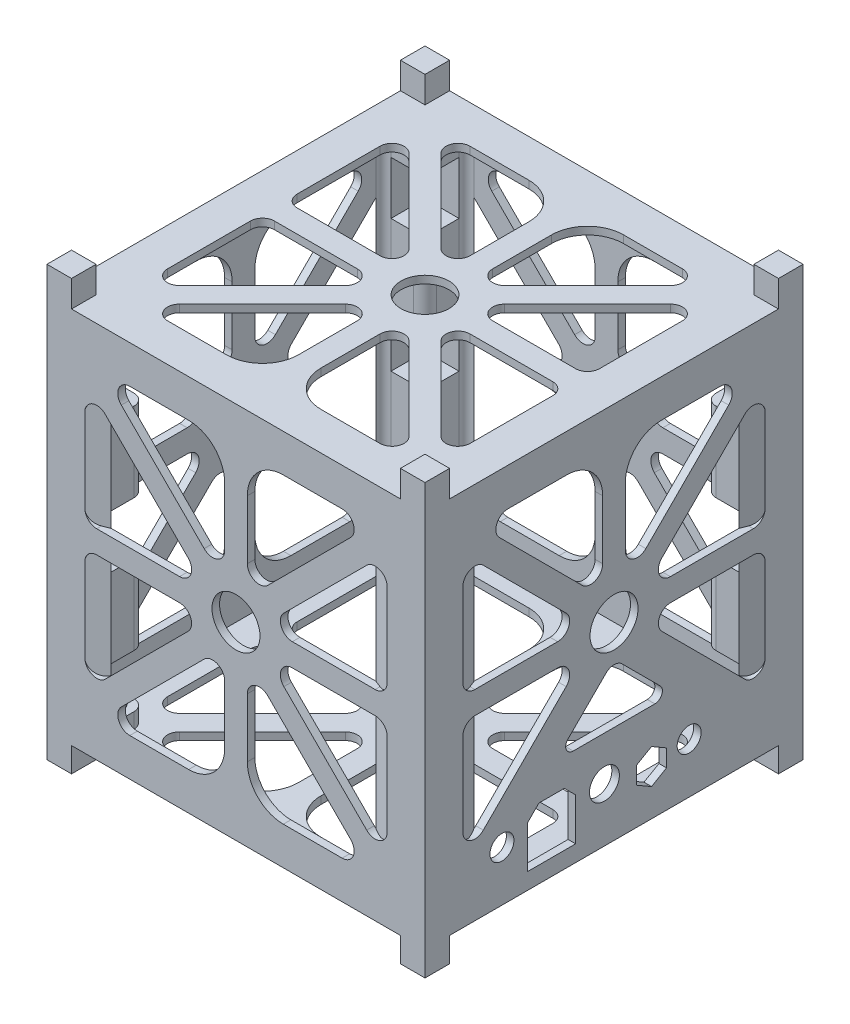
from build123d import *

# Parameters (mm, degrees)
SKETCH1_W                = 100
SKETCH1_H                = 100
BOSS_EXTRUDE1_DEPTH      = 50
SKETCH2_W                = 6.5
SKETCH2_H                = 6.5
BOSS_EXTRUDE2_DEPTH      = 57
BOSS_EXTRUDE2_DEPTH_BACK = 56.5
SKETCH4_W                = 96
SKETCH4_H                = 96
CUT_EXTRUDE1_DEPTH       = 96
SKETCH6_R                = 6.35
CUT_EXTRUDE4_DEPTH       = 2
CUT_EXTRUDE2_REACH       = 102
SKETCH5_R                = 3.175
SKETCH5_R_2              = 3.9624
SKETCH5_R_3              = 6.35
BOSS_EXTRUDE3_REACH      = 106.5
CUT_EXTRUDE5_START       = 78
SKETCH10_R               = 1.5
CUT_EXTRUDE5_DEPTH       = 2
CUT_EXTRUDE6_START       = 80
SKETCH13_R               = 1.5
CUT_EXTRUDE6_DEPTH       = 12
CUT_EXTRUDE7_START       = 80
SKETCH13_3_R             = 1.5
CUT_EXTRUDE7_DEPTH       = 14
BOSS_EXTRUDE4_DEPTH      = 100
MIRROR6_COPY_1_DEPTH     = 100
MIRROR6_COPY_2_DEPTH     = 100
MIRROR7_COPY_1_DEPTH     = 100
MIRROR7_COPY_2_DEPTH     = 100
MIRROR7_COPY_3_DEPTH     = 100
CUT_EXTRUDE11_DEPTH      = 3
BOSS_EXTRUDE5_DEPTH      = 98
SKETCH18_R               = 6.35
CUT_EXTRUDE13_DEPTH      = 107.5
LPATTERN1_COUNT          = 3
LPATTERN1_PITCH          = 35


with BuildPart() as part:
    # Sketch1 → Boss-Extrude1 (new body, symmetric)
    with BuildSketch(Plane(origin=(0, 0, 0), x_dir=(1, 0, 0), z_dir=(0, 1, 0))):
        Rectangle(SKETCH1_W, SKETCH1_H)
    extrude(amount=BOSS_EXTRUDE1_DEPTH, both=True)

    # Sketch2 → Boss-Extrude2 (add, two sides)
    with BuildSketch(Plane(origin=(0, 0, 0), x_dir=(1, 0, 0), z_dir=(0, 1, 0))) as boss_extrude2_sk:
        with Locations((-46.75, -46.75)):
            Rectangle(SKETCH2_W, SKETCH2_H)
        with Locations((46.75, -46.75)):
            Rectangle(SKETCH2_W, SKETCH2_H)
        with Locations((46.75, 46.75)):
            Rectangle(SKETCH2_W, SKETCH2_H)
        with Locations((-46.75, 46.75)):
            Rectangle(SKETCH2_W, SKETCH2_H)
    extrude(amount=BOSS_EXTRUDE2_DEPTH)
    extrude(boss_extrude2_sk.sketch, amount=-BOSS_EXTRUDE2_DEPTH_BACK)

    # Sketch4 → Cut-Extrude1 (cut)
    with BuildSketch(Plane(origin=(48, 0, 0), x_dir=(0, 0, -1), z_dir=(1, 0, 0))):
        Rectangle(SKETCH4_W, SKETCH4_H)
    extrude(amount=-CUT_EXTRUDE1_DEPTH, mode=Mode.SUBTRACT)

    # Sketch6 → Cut-Extrude4 (cut)
    with BuildSketch(Plane.XY.offset(50)):
        with BuildLine():
            ThreePointArc((-3, -30.475), (-5.789807909, -37.210192091), (-12.525, -40))
            Line((-12.525, -40), (-28.092231252, -40))
            ThreePointArc((-28.092231252, -40), (-31.025548768, -38.040019898), (-30.337295283, -34.57993597))
            Line((-30.337295283, -34.57993597), (-8.42006403, -12.662704717))
            ThreePointArc((-8.42006403, -12.662704717), (-4.959980102, -11.974451232), (-3, -14.907768748))
            Line((-3, -14.907768748), (-3, -30.475))
        make_face()
        with BuildLine():
            ThreePointArc((-14.907768748, -3), (-11.974451232, -4.959980102), (-12.662704717, -8.42006403))
            Line((-12.662704717, -8.42006403), (-34.57993597, -30.337295283))
            ThreePointArc((-34.57993597, -30.337295283), (-38.040019898, -31.025548768), (-40, -28.092231252))
            Line((-40, -28.092231252), (-40, -6.175))
            ThreePointArc((-40, -6.175), (-39.07006403, -3.92993597), (-36.825, -3))
            Line((-36.825, -3), (-14.907768748, -3))
        make_face()
        with BuildLine():
            ThreePointArc((-40, 28.092231252), (-38.040019898, 31.025548768), (-34.57993597, 30.337295283))
            Line((-34.57993597, 30.337295283), (-12.662704717, 8.42006403))
            ThreePointArc((-12.662704717, 8.42006403), (-11.974451232, 4.959980102), (-14.907768748, 3))
            Line((-14.907768748, 3), (-36.825, 3))
            ThreePointArc((-36.825, 3), (-39.07006403, 3.92993597), (-40, 6.175))
            Line((-40, 6.175), (-40, 28.092231252))
        make_face()
        with BuildLine():
            Line((-30.337295283, 34.57993597), (-8.42006403, 12.662704717))
            ThreePointArc((-8.42006403, 12.662704717), (-4.959980102, 11.974451232), (-3, 14.907768748))
            Line((-3, 14.907768748), (-3, 30.475))
            ThreePointArc((-3, 30.475), (-5.789807909, 37.210192091), (-12.525, 40))
            Line((-12.525, 40), (-28.092231252, 40))
            ThreePointArc((-28.092231252, 40), (-31.025548768, 38.040019898), (-30.337295283, 34.57993597))
        make_face()
        with BuildLine():
            Line((30.337295283, 34.57993597), (8.42006403, 12.662704717))
            ThreePointArc((8.42006403, 12.662704717), (4.959980102, 11.974451232), (3, 14.907768748))
            Line((3, 14.907768748), (3, 30.475))
            ThreePointArc((3, 30.475), (5.789807909, 37.210192091), (12.525, 40))
            Line((12.525, 40), (28.092231252, 40))
            ThreePointArc((28.092231252, 40), (31.025548768, 38.040019898), (30.337295283, 34.57993597))
        make_face()
        with BuildLine():
            Line((12.662704717, 8.42006403), (34.57993597, 30.337295283))
            ThreePointArc((34.57993597, 30.337295283), (38.040019898, 31.025548768), (40, 28.092231252))
            Line((40, 28.092231252), (40, 6.175))
            ThreePointArc((40, 6.175), (39.07006403, 3.92993597), (36.825, 3))
            Line((36.825, 3), (14.907768748, 3))
            ThreePointArc((14.907768748, 3), (11.974451232, 4.959980102), (12.662704717, 8.42006403))
        make_face()
        with BuildLine():
            Line((34.57993597, -30.337295283), (12.662704717, -8.42006403))
            ThreePointArc((12.662704717, -8.42006403), (11.974451232, -4.959980102), (14.907768748, -3))
            Line((14.907768748, -3), (36.825, -3))
            ThreePointArc((36.825, -3), (39.07006403, -3.92993597), (40, -6.175))
            Line((40, -6.175), (40, -28.092231252))
            ThreePointArc((40, -28.092231252), (38.040019898, -31.025548768), (34.57993597, -30.337295283))
        make_face()
        with BuildLine():
            ThreePointArc((30.337295283, -34.57993597), (31.025548768, -38.040019898), (28.092231252, -40))
            Line((28.092231252, -40), (12.525, -40))
            ThreePointArc((12.525, -40), (5.789807909, -37.210192091), (3, -30.475))
            Line((3, -30.475), (3, -14.907768748))
            ThreePointArc((3, -14.907768748), (4.959980102, -11.974451232), (8.42006403, -12.662704717))
            Line((8.42006403, -12.662704717), (30.337295283, -34.57993597))
        make_face()
        Circle(SKETCH6_R)
    cut_extrude4 = extrude(amount=-CUT_EXTRUDE4_DEPTH, mode=Mode.SUBTRACT)

    # Sketch5 → Cut-Extrude2 (cut, up to next)
    with BuildSketch(Plane(origin=(50, 0, 0), x_dir=(0, 0, -1), z_dir=(1, 0, 0)), mode=Mode.PRIVATE) as cut_extrude2_sk1:
        with BuildLine():
            Line((-3, 14.907768748), (-3, 30.475))
            ThreePointArc((-3, 30.475), (-5.789807909, 37.210192091), (-12.525, 40))
            Line((-12.525, 40), (-28.092231252, 40))
            ThreePointArc((-28.092231252, 40), (-31.025548768, 38.040019898), (-30.337295283, 34.57993597))
            Line((-30.337295283, 34.57993597), (-8.42006403, 12.662704717))
            ThreePointArc((-8.42006403, 12.662704717), (-4.959980102, 11.974451232), (-3, 14.907768748))
        make_face()
    cut_extrude2_tool1 = extrude(cut_extrude2_sk1.sketch, amount=-CUT_EXTRUDE2_REACH, mode=Mode.PRIVATE) & part.part
    add(cut_extrude2_tool1.solids().sort_by_distance((50, 28.959024, 14.040976))[0], mode=Mode.SUBTRACT)
    # Sketch5 → Cut-Extrude2 (cut, up to next)
    with BuildSketch(Plane(origin=(50, 0, 0), x_dir=(0, 0, -1), z_dir=(1, 0, 0)), mode=Mode.PRIVATE) as cut_extrude2_sk2:
        Polygon((-10.156, -34.48), (-13.156, -31.48), (-19.864, -31.48), (-22.864, -34.48), (-22.864, -45.686), (-10.156, -45.686), align=None)
    cut_extrude2_tool2 = extrude(cut_extrude2_sk2.sketch, amount=-CUT_EXTRUDE2_REACH, mode=Mode.PRIVATE) & part.part
    add(cut_extrude2_tool2.solids().sort_by_distance((50, -38.903218, 16.51))[0], mode=Mode.SUBTRACT)
    # Sketch5 → Cut-Extrude2 (cut, up to next)
    with BuildSketch(Plane(origin=(50, 0, 0), x_dir=(0, 0, -1), z_dir=(1, 0, 0)), mode=Mode.PRIVATE) as cut_extrude2_sk3:
        with BuildLine():
            Line((40, -28.092231252), (40, -6.175))
            ThreePointArc((40, -6.175), (39.07006403, -3.92993597), (36.825, -3))
            Line((36.825, -3), (14.907768748, -3))
            ThreePointArc((14.907768748, -3), (11.974451232, -4.959980102), (12.662704717, -8.42006403))
            Line((12.662704717, -8.42006403), (34.57993597, -30.337295283))
            ThreePointArc((34.57993597, -30.337295283), (38.040019898, -31.025548768), (40, -28.092231252))
        make_face()
    cut_extrude2_tool3 = extrude(cut_extrude2_sk3.sketch, amount=-CUT_EXTRUDE2_REACH, mode=Mode.PRIVATE) & part.part
    add(cut_extrude2_tool3.solids().sort_by_distance((50, -13.744194, -29.255806))[0], mode=Mode.SUBTRACT)
    # Sketch5 → Cut-Extrude2 (cut, up to next)
    with BuildSketch(Plane(origin=(50, 0, 0), x_dir=(0, 0, -1), z_dir=(1, 0, 0)), mode=Mode.PRIVATE) as cut_extrude2_sk4:
        with BuildLine():
            ThreePointArc((-40, -28.092231252), (-38.040019898, -31.025548768), (-34.57993597, -30.337295283))
            Line((-34.57993597, -30.337295283), (-12.662704717, -8.42006403))
            ThreePointArc((-12.662704717, -8.42006403), (-11.974451232, -4.959980102), (-14.907768748, -3))
            Line((-14.907768748, -3), (-36.825, -3))
            ThreePointArc((-36.825, -3), (-39.07006403, -3.92993597), (-40, -6.175))
            Line((-40, -6.175), (-40, -28.092231252))
        make_face()
    cut_extrude2_tool4 = extrude(cut_extrude2_sk4.sketch, amount=-CUT_EXTRUDE2_REACH, mode=Mode.PRIVATE) & part.part
    add(cut_extrude2_tool4.solids().sort_by_distance((50, -13.744194, 29.255806))[0], mode=Mode.SUBTRACT)
    # Sketch5 → Cut-Extrude2 (cut, up to next)
    with BuildSketch(Plane(origin=(50, 0, 0), x_dir=(0, 0, -1), z_dir=(1, 0, 0)), mode=Mode.PRIVATE) as cut_extrude2_sk5:
        with BuildLine():
            ThreePointArc((-40, 6.175), (-39.07006403, 3.92993597), (-36.825, 3))
            Line((-36.825, 3), (-14.907768748, 3))
            ThreePointArc((-14.907768748, 3), (-11.974451232, 4.959980102), (-12.662704717, 8.42006403))
            Line((-12.662704717, 8.42006403), (-34.57993597, 30.337295283))
            ThreePointArc((-34.57993597, 30.337295283), (-38.040019898, 31.025548768), (-40, 28.092231252))
            Line((-40, 28.092231252), (-40, 6.175))
        make_face()
    cut_extrude2_tool5 = extrude(cut_extrude2_sk5.sketch, amount=-CUT_EXTRUDE2_REACH, mode=Mode.PRIVATE) & part.part
    add(cut_extrude2_tool5.solids().sort_by_distance((50, 13.744194, 29.255806))[0], mode=Mode.SUBTRACT)
    # Sketch5 → Cut-Extrude2 (cut, up to next)
    with BuildSketch(Plane(origin=(50, 0, 0), x_dir=(0, 0, -1), z_dir=(1, 0, 0)), mode=Mode.PRIVATE) as cut_extrude2_sk6:
        with BuildLine():
            Line((12.213897948, -20.692427125), (2.124696443, -10.603225619))
            ThreePointArc((2.124696443, -10.603225619), (0.003376099, -9.724545962), (-2.117944245, -10.603225619))
            Line((-2.117944245, -10.603225619), (-12.207145751, -20.692427125))
            ThreePointArc((-12.207145751, -20.692427125), (-12.640691253, -22.872007552), (-10.792932188, -24.106640687))
            Line((-10.792932188, -24.106640687), (10.799684386, -24.106640687))
            ThreePointArc((10.799684386, -24.106640687), (12.647443451, -22.872007552), (12.213897948, -20.692427125))
        make_face()
    cut_extrude2_tool6 = extrude(cut_extrude2_sk6.sketch, amount=-CUT_EXTRUDE2_REACH, mode=Mode.PRIVATE) & part.part
    add(cut_extrude2_tool6.solids().sort_by_distance((50, -18.793244, -0.003376))[0], mode=Mode.SUBTRACT)
    # Sketch5 → Cut-Extrude2 (cut, up to next)
    with BuildSketch(Plane(origin=(50, 0, 0), x_dir=(0, 0, -1), z_dir=(1, 0, 0)), mode=Mode.PRIVATE) as cut_extrude2_sk7:
        with Locations((-29.65, -36.726)):
            Circle(SKETCH5_R)
    cut_extrude2_tool7 = extrude(cut_extrude2_sk7.sketch, amount=-CUT_EXTRUDE2_REACH, mode=Mode.PRIVATE) & part.part
    add(cut_extrude2_tool7.solids().sort_by_distance((50, -36.726, 29.65))[0], mode=Mode.SUBTRACT)
    # Sketch5 → Cut-Extrude2 (cut, up to next)
    with BuildSketch(Plane(origin=(50, 0, 0), x_dir=(0, 0, -1), z_dir=(1, 0, 0)), mode=Mode.PRIVATE) as cut_extrude2_sk8:
        with BuildLine():
            Line((3, 30.475), (3, 14.907768748))
            ThreePointArc((3, 14.907768748), (4.959980102, 11.974451232), (8.42006403, 12.662704717))
            Line((8.42006403, 12.662704717), (30.337295283, 34.57993597))
            ThreePointArc((30.337295283, 34.57993597), (31.025548768, 38.040019898), (28.092231252, 40))
            Line((28.092231252, 40), (12.525, 40))
            ThreePointArc((12.525, 40), (5.789807909, 37.210192091), (3, 30.475))
        make_face()
    cut_extrude2_tool8 = extrude(cut_extrude2_sk8.sketch, amount=-CUT_EXTRUDE2_REACH, mode=Mode.PRIVATE) & part.part
    add(cut_extrude2_tool8.solids().sort_by_distance((50, 28.959024, -14.040976))[0], mode=Mode.SUBTRACT)
    # Sketch5 → Cut-Extrude2 (cut, up to next)
    with BuildSketch(Plane(origin=(50, 0, 0), x_dir=(0, 0, -1), z_dir=(1, 0, 0)), mode=Mode.PRIVATE) as cut_extrude2_sk9:
        with BuildLine():
            Line((34.57993597, 30.337295283), (12.662704717, 8.42006403))
            ThreePointArc((12.662704717, 8.42006403), (11.974451232, 4.959980102), (14.907768748, 3))
            Line((14.907768748, 3), (36.825, 3))
            ThreePointArc((36.825, 3), (39.07006403, 3.92993597), (40, 6.175))
            Line((40, 6.175), (40, 28.092231252))
            ThreePointArc((40, 28.092231252), (38.040019898, 31.025548768), (34.57993597, 30.337295283))
        make_face()
    cut_extrude2_tool9 = extrude(cut_extrude2_sk9.sketch, amount=-CUT_EXTRUDE2_REACH, mode=Mode.PRIVATE) & part.part
    add(cut_extrude2_tool9.solids().sort_by_distance((50, 13.744194, -29.255806))[0], mode=Mode.SUBTRACT)
    # Sketch5 → Cut-Extrude2 (cut, up to next)
    with BuildSketch(Plane(origin=(50, 0, 0), x_dir=(0, 0, -1), z_dir=(1, 0, 0)), mode=Mode.PRIVATE) as cut_extrude2_sk10:
        Polygon((5.94995, -40.313658881), (9.9187, -42.605017762), (13.88745, -40.313658881), (13.88745, -35.730941119), (9.9187, -33.439582238), (5.94995, -35.730941119), align=None)
    cut_extrude2_tool10 = extrude(cut_extrude2_sk10.sketch, amount=-CUT_EXTRUDE2_REACH, mode=Mode.PRIVATE) & part.part
    add(cut_extrude2_tool10.solids().sort_by_distance((50, -38.0223, -9.9187))[0], mode=Mode.SUBTRACT)
    # Sketch5 → Cut-Extrude2 (cut, up to next)
    with BuildSketch(Plane(origin=(50, 0, 0), x_dir=(0, 0, -1), z_dir=(1, 0, 0)), mode=Mode.PRIVATE) as cut_extrude2_sk11:
        with Locations((19.8756, -36.726)):
            Circle(SKETCH5_R)
    cut_extrude2_tool11 = extrude(cut_extrude2_sk11.sketch, amount=-CUT_EXTRUDE2_REACH, mode=Mode.PRIVATE) & part.part
    add(cut_extrude2_tool11.solids().sort_by_distance((50, -36.726, -19.8756))[0], mode=Mode.SUBTRACT)
    # Sketch5 → Cut-Extrude2 (cut, up to next)
    with BuildSketch(Plane(origin=(50, 0, 0), x_dir=(0, 0, -1), z_dir=(1, 0, 0)), mode=Mode.PRIVATE) as cut_extrude2_sk12:
        with Locations((-2.54, -35.749)):
            Circle(SKETCH5_R_2)
    cut_extrude2_tool12 = extrude(cut_extrude2_sk12.sketch, amount=-CUT_EXTRUDE2_REACH, mode=Mode.PRIVATE) & part.part
    add(cut_extrude2_tool12.solids().sort_by_distance((50, -35.749, 2.54))[0], mode=Mode.SUBTRACT)
    # Sketch5 → Cut-Extrude2 (cut, up to next)
    with BuildSketch(Plane(origin=(50, 0, 0), x_dir=(0, 0, -1), z_dir=(1, 0, 0)), mode=Mode.PRIVATE) as cut_extrude2_sk13:
        with Locations((0.003376099, 0.003376099)):
            Circle(SKETCH5_R_3)
    cut_extrude2_tool13 = extrude(cut_extrude2_sk13.sketch, amount=-CUT_EXTRUDE2_REACH, mode=Mode.PRIVATE) & part.part
    add(cut_extrude2_tool13.solids().sort_by_distance((50, 0.003376, -0.003376))[0], mode=Mode.SUBTRACT)

    # Mirror3: Cut-Extrude4 across plane
    add(cut_extrude4.mirror(Plane.XY), mode=Mode.SUBTRACT)

    # Mirror4: Cut-Extrude4 across plane
    add(cut_extrude4.mirror(Plane(origin=(0, 0, 0), x_dir=(-0.707106781, 0, 0.707106781), z_dir=(-0.707106781, 0, -0.707106781))), mode=Mode.SUBTRACT)

    # Sketch7 → Boss-Extrude3 (add, up to next)
    with BuildSketch(Plane.XZ.offset(-48), mode=Mode.PRIVATE) as boss_extrude3_sk1:
        with BuildLine():
            Line((35, -48), (48, -48))
            Line((48, -48), (48, -35))
            ThreePointArc((48, -35), (47.414213562, -36.414213562), (46, -37))
            Line((46, -37), (40, -37))
            ThreePointArc((40, -37), (37.878679656, -37.878679656), (37, -40))
            Line((37, -40), (37, -46))
            ThreePointArc((37, -46), (36.414213562, -47.414213562), (35, -48))
        make_face()
    boss_extrude3_tool1 = extrude(boss_extrude3_sk1.sketch, amount=BOSS_EXTRUDE3_REACH, mode=Mode.PRIVATE) - part.part
    add(boss_extrude3_tool1.solids().sort_by_distance((42.570883, 48, -42.570883))[0])
    # Sketch7 → Boss-Extrude3 (add, up to next)
    with BuildSketch(Plane.XZ.offset(-48), mode=Mode.PRIVATE) as boss_extrude3_sk2:
        with BuildLine():
            Line((48, 35), (48, 48))
            Line((48, 48), (35, 48))
            ThreePointArc((35, 48), (36.414213562, 47.414213562), (37, 46))
            Line((37, 46), (37, 40))
            ThreePointArc((37, 40), (37.878679656, 37.878679656), (40, 37))
            Line((40, 37), (46, 37))
            ThreePointArc((46, 37), (47.414213562, 36.414213562), (48, 35))
        make_face()
    boss_extrude3_tool2 = extrude(boss_extrude3_sk2.sketch, amount=BOSS_EXTRUDE3_REACH, mode=Mode.PRIVATE) - part.part
    add(boss_extrude3_tool2.solids().sort_by_distance((42.570883, 48, 42.570883))[0])
    # Sketch7 → Boss-Extrude3 (add, up to next)
    with BuildSketch(Plane.XZ.offset(-48), mode=Mode.PRIVATE) as boss_extrude3_sk3:
        with BuildLine():
            Line((-35, 48), (-48, 48))
            Line((-48, 48), (-48, 35))
            ThreePointArc((-48, 35), (-47.414213562, 36.414213562), (-46, 37))
            Line((-46, 37), (-40, 37))
            ThreePointArc((-40, 37), (-37.878679656, 37.878679656), (-37, 40))
            Line((-37, 40), (-37, 46))
            ThreePointArc((-37, 46), (-36.414213562, 47.414213562), (-35, 48))
        make_face()
    boss_extrude3_tool3 = extrude(boss_extrude3_sk3.sketch, amount=BOSS_EXTRUDE3_REACH, mode=Mode.PRIVATE) - part.part
    add(boss_extrude3_tool3.solids().sort_by_distance((-42.570883, 48, 42.570883))[0])
    # Sketch7 → Boss-Extrude3 (add, up to next)
    with BuildSketch(Plane.XZ.offset(-48), mode=Mode.PRIVATE) as boss_extrude3_sk4:
        with BuildLine():
            Line((-48, -35), (-48, -48))
            Line((-48, -48), (-35, -48))
            ThreePointArc((-35, -48), (-36.414213562, -47.414213562), (-37, -46))
            Line((-37, -46), (-37, -40))
            ThreePointArc((-37, -40), (-37.878679656, -37.878679656), (-40, -37))
            Line((-40, -37), (-46, -37))
            ThreePointArc((-46, -37), (-47.414213562, -36.414213562), (-48, -35))
        make_face()
    boss_extrude3_tool4 = extrude(boss_extrude3_sk4.sketch, amount=BOSS_EXTRUDE3_REACH, mode=Mode.PRIVATE) - part.part
    add(boss_extrude3_tool4.solids().sort_by_distance((-42.570883, 48, -42.570883))[0])

    # Sketch10 → Cut-Extrude5 (cut)
    with BuildSketch(Plane.XZ.offset(-48).offset(CUT_EXTRUDE5_START)):
        with BuildLine():
            Line((-48, -48), (-39, -48))
            Line((-39, -48), (-39, -46))
            Line((-39, -46), (-37, -46))
            Line((-37, -46), (-37, -40))
            ThreePointArc((-37, -40), (-37.878679656, -37.878679656), (-40, -37))
            Line((-40, -37), (-46, -37))
            Line((-46, -37), (-46, -39))
            Line((-46, -39), (-48, -39))
            Line((-48, -39), (-48, -48))
        make_face()
        with Locations((-40.5, -40.5)):
            Circle(SKETCH10_R, mode=Mode.SUBTRACT)
        with Locations((-40.5, -40.5)):
            Circle(SKETCH10_R)
        with BuildLine():
            Line((46, -37), (46, -39))
            Line((46, -39), (48, -39))
            Line((48, -39), (48, -48))
            Line((48, -48), (39, -48))
            Line((39, -48), (39, -46))
            Line((39, -46), (37, -46))
            Line((37, -46), (37, -40))
            ThreePointArc((37, -40), (37.878679656, -37.878679656), (40, -37))
            Line((40, -37), (46, -37))
        make_face()
        with Locations((40.5, -40.5)):
            Circle(SKETCH10_R, mode=Mode.SUBTRACT)
        with Locations((40.5, -40.5)):
            Circle(SKETCH10_R)
        with BuildLine():
            Line((48, 48), (39, 48))
            Line((39, 48), (39, 46))
            Line((39, 46), (37, 46))
            Line((37, 46), (37, 40))
            ThreePointArc((37, 40), (37.878679656, 37.878679656), (40, 37))
            Line((40, 37), (46, 37))
            Line((46, 37), (46, 39))
            Line((46, 39), (48, 39))
            Line((48, 39), (48, 48))
        make_face()
        with Locations((40.5, 40.5)):
            Circle(SKETCH10_R, mode=Mode.SUBTRACT)
        with Locations((40.5, 40.5)):
            Circle(SKETCH10_R)
        with BuildLine():
            Line((-46, 37), (-46, 39))
            Line((-46, 39), (-48, 39))
            Line((-48, 39), (-48, 48))
            Line((-48, 48), (-39, 48))
            Line((-39, 48), (-39, 46))
            Line((-39, 46), (-37, 46))
            Line((-37, 46), (-37, 40))
            ThreePointArc((-37, 40), (-37.878679656, 37.878679656), (-40, 37))
            Line((-40, 37), (-46, 37))
        make_face()
        with Locations((-40.5, 40.5)):
            Circle(SKETCH10_R, mode=Mode.SUBTRACT)
        with Locations((-40.5, 40.5)):
            Circle(SKETCH10_R)
    cut_extrude5 = extrude(amount=CUT_EXTRUDE5_DEPTH, mode=Mode.SUBTRACT)

    # Sketch13 → Cut-Extrude6 (cut)
    with BuildSketch(Plane.XZ.offset(-48).offset(CUT_EXTRUDE6_START)):
        with BuildLine():
            Line((37, 46), (46, 46))
            Line((46, 46), (46, 37))
            Line((46, 37), (40, 37))
            ThreePointArc((40, 37), (37.878679656, 37.878679656), (37, 40))
            Line((37, 40), (37, 46))
        make_face()
        with Locations((40.5, 40.5)):
            Circle(SKETCH13_R, mode=Mode.SUBTRACT)
        with Locations((40.5, 40.5)):
            Circle(SKETCH13_R)
        with BuildLine():
            Line((46, -37), (46, -46))
            Line((46, -46), (37, -46))
            Line((37, -46), (37, -40))
            ThreePointArc((37, -40), (37.878679656, -37.878679656), (40, -37))
            Line((40, -37), (46, -37))
        make_face()
        with Locations((40.5, -40.5)):
            Circle(SKETCH13_R, mode=Mode.SUBTRACT)
        with BuildLine():
            Line((-37, -46), (-46, -46))
            Line((-46, -46), (-46, -37))
            Line((-46, -37), (-40, -37))
            ThreePointArc((-40, -37), (-37.878679656, -37.878679656), (-37, -40))
            Line((-37, -40), (-37, -46))
        make_face()
        with Locations((-40.5, -40.5)):
            Circle(SKETCH13_R, mode=Mode.SUBTRACT)
        with Locations((-40.5, -40.5)):
            Circle(SKETCH13_R)
        with BuildLine():
            Line((-37, 46), (-46, 46))
            Line((-46, 46), (-46, 37))
            Line((-46, 37), (-40, 37))
            ThreePointArc((-40, 37), (-37.878679656, 37.878679656), (-37, 40))
            Line((-37, 40), (-37, 46))
        make_face()
        with Locations((-40.5, 40.5)):
            Circle(SKETCH13_R, mode=Mode.SUBTRACT)
        with Locations((-40.5, 40.5)):
            Circle(SKETCH13_R)
        with Locations((40.5, -40.5)):
            Circle(SKETCH13_R)
    cut_extrude6 = extrude(amount=CUT_EXTRUDE6_DEPTH, mode=Mode.SUBTRACT)

    # Sketch13_3 → Cut-Extrude7 (cut)
    with BuildSketch(Plane.XZ.offset(-48).offset(CUT_EXTRUDE7_START)):
        with Locations((40.5, 40.5)):
            Circle(SKETCH13_3_R)
        with Locations((-40.5, 40.5)):
            Circle(SKETCH13_3_R)
        with Locations((-40.5, -40.5)):
            Circle(SKETCH13_3_R)
        with Locations((40.5, -40.5)):
            Circle(SKETCH13_3_R)
    cut_extrude7 = extrude(amount=CUT_EXTRUDE7_DEPTH, mode=Mode.SUBTRACT)

    # Sketch15 → Boss-Extrude4 (add, through all)
    with BuildSketch(Plane(origin=(0, 0, -50), x_dir=(-1, 0, 0), z_dir=(0, 0, -1))):
        Polygon((-48, 41.080632081), (-41.080632081, 48), (-48, 48), align=None)
    boss_extrude4 = extrude(amount=-BOSS_EXTRUDE4_DEPTH)

    # Mirror5: Boss-Extrude4 across plane
    add(boss_extrude4.mirror(Plane(origin=(0, 0, 0), x_dir=(-0.707106781, 0, 0.707106781), z_dir=(-0.707106781, 0, -0.707106781))))

    # Mirror6 copy 1 sketch → Mirror6 copy 1 (add, through all)
    with BuildSketch(Plane.ZY.offset(50)):
        Polygon((-48, 41.080632081), (-41.080632081, 48), (-48, 48), align=None)
    extrude(amount=-MIRROR6_COPY_1_DEPTH)

    # Mirror6 copy 2 sketch → Mirror6 copy 2 (add, through all)
    with BuildSketch(Plane(origin=(0, 0, -50), x_dir=(1, 0, 0), z_dir=(0, 0, -1))):
        Polygon((-48, -41.080632081), (-41.080632081, -48), (-48, -48), align=None)
    extrude(amount=-MIRROR6_COPY_2_DEPTH)

    # Mirror7 copy 1 sketch → Mirror7 copy 1 (add, through all)
    with BuildSketch(Plane(origin=(0, 0, 50), x_dir=(-1, 0, 0), z_dir=(0, 0, 1))):
        Polygon((-48, -41.080632081), (-41.080632081, -48), (-48, -48), align=None)
    extrude(amount=-MIRROR7_COPY_1_DEPTH)

    # Mirror7 copy 2 sketch → Mirror7 copy 2 (add, through all)
    with BuildSketch(Plane(origin=(50, 0, 0), x_dir=(0, 0, -1), z_dir=(1, 0, 0))):
        Polygon((-48, 41.080632081), (-41.080632081, 48), (-48, 48), align=None)
    extrude(amount=-MIRROR7_COPY_2_DEPTH)

    # Mirror7 copy 3 sketch → Mirror7 copy 3 (add, through all)
    with BuildSketch(Plane(origin=(50, 0, 0), x_dir=(0, 0, 1), z_dir=(1, 0, 0))):
        Polygon((-48, -41.080632081), (-41.080632081, -48), (-48, -48), align=None)
    extrude(amount=-MIRROR7_COPY_3_DEPTH)

    # Sketch14 → Cut-Extrude11 (cut)
    with BuildSketch(Plane.XZ.offset(-48)):
        Polygon((-48, -35), (-48, -4), (-40, -4), (-40, 4), (-48, 4), (-48, 35), (-35, 48), (-4, 48), (-4, 40), (4, 40), (4, 48), (35, 48), (48, 35), (48, 4), (40, 4), (40, -4), (48, -4), (48, -35), (35, -48), (4, -48), (4, -40), (-4, -40), (-4, -48), (-35, -48), align=None)
    extrude(amount=CUT_EXTRUDE11_DEPTH, mode=Mode.SUBTRACT)

    # Sketch16 → Boss-Extrude5 (add)
    with BuildSketch(Plane.XZ.offset(-48)):
        Polygon((-48, 35), (-50, 40), (-48, 40), align=None)
        Polygon((-40, 48), (-35, 48), (-40, 50), align=None)
        Polygon((48, -35), (50, -40), (48, -40), align=None)
        Polygon((40, -48), (35, -48), (40, -50), align=None)
        Polygon((35, 48), (40, 50), (40, 48), align=None)
        Polygon((48, 40), (48, 35), (50, 40), align=None)
        Polygon((-35, -48), (-40, -50), (-40, -48), align=None)
        Polygon((-48, -40), (-48, -35), (-50, -40), align=None)
    extrude(amount=BOSS_EXTRUDE5_DEPTH)

    # Sketch18 → Cut-Extrude13 (cut, through all)
    with BuildSketch(Plane(origin=(0, 50, 0), x_dir=(1, 0, 0), z_dir=(0, 1, 0))):
        with BuildLine():
            Line((-30.337295283, 34.57993597), (-8.42006403, 12.662704717))
            ThreePointArc((-8.42006403, 12.662704717), (-4.959980102, 11.974451232), (-3, 14.907768748))
            Line((-3, 14.907768748), (-3, 30.475))
            ThreePointArc((-3, 30.475), (-5.789807909, 37.210192091), (-12.525, 40))
            Line((-12.525, 40), (-28.092231252, 40))
            ThreePointArc((-28.092231252, 40), (-31.025548768, 38.040019898), (-30.337295283, 34.57993597))
        make_face()
        with BuildLine():
            Line((30.337295283, 34.57993597), (8.42006403, 12.662704717))
            ThreePointArc((8.42006403, 12.662704717), (4.959980102, 11.974451232), (3, 14.907768748))
            Line((3, 14.907768748), (3, 30.475))
            ThreePointArc((3, 30.475), (5.789807909, 37.210192091), (12.525, 40))
            Line((12.525, 40), (28.092231252, 40))
            ThreePointArc((28.092231252, 40), (31.025548768, 38.040019898), (30.337295283, 34.57993597))
        make_face()
        with BuildLine():
            Line((12.662704717, 8.42006403), (34.57993597, 30.337295283))
            ThreePointArc((34.57993597, 30.337295283), (38.040019898, 31.025548768), (40, 28.092231252))
            Line((40, 28.092231252), (40, 6.175))
            ThreePointArc((40, 6.175), (39.07006403, 3.92993597), (36.825, 3))
            Line((36.825, 3), (14.907768748, 3))
            ThreePointArc((14.907768748, 3), (11.974451232, 4.959980102), (12.662704717, 8.42006403))
        make_face()
        with BuildLine():
            Line((34.57993597, -30.337295283), (12.662704717, -8.42006403))
            ThreePointArc((12.662704717, -8.42006403), (11.974451232, -4.959980102), (14.907768747, -3))
            Line((14.907768747, -3), (36.825, -3))
            ThreePointArc((36.825, -3), (39.07006403, -3.92993597), (40, -6.175))
            Line((40, -6.175), (40, -28.092231252))
            ThreePointArc((40, -28.092231252), (38.040019898, -31.025548768), (34.57993597, -30.337295283))
        make_face()
        with BuildLine():
            ThreePointArc((30.337295283, -34.57993597), (31.025548768, -38.040019898), (28.092231252, -40))
            Line((28.092231252, -40), (12.525, -40))
            ThreePointArc((12.525, -40), (5.789807909, -37.210192091), (3, -30.475))
            Line((3, -30.475), (3, -14.907768748))
            ThreePointArc((3, -14.907768748), (4.959980102, -11.974451232), (8.42006403, -12.662704717))
            Line((8.42006403, -12.662704717), (30.337295283, -34.57993597))
        make_face()
        with BuildLine():
            ThreePointArc((-3, -30.475), (-5.789807909, -37.210192091), (-12.525, -40))
            Line((-12.525, -40), (-28.092231252, -40))
            ThreePointArc((-28.092231252, -40), (-31.025548768, -38.040019898), (-30.337295283, -34.57993597))
            Line((-30.337295283, -34.57993597), (-8.42006403, -12.662704717))
            ThreePointArc((-8.42006403, -12.662704717), (-4.959980102, -11.974451232), (-3, -14.907768748))
            Line((-3, -14.907768748), (-3, -30.475))
        make_face()
        with BuildLine():
            ThreePointArc((-14.907768747, -3), (-11.974451232, -4.959980102), (-12.662704717, -8.42006403))
            Line((-12.662704717, -8.42006403), (-34.57993597, -30.337295283))
            ThreePointArc((-34.57993597, -30.337295283), (-38.040019898, -31.025548768), (-40, -28.092231252))
            Line((-40, -28.092231252), (-40, -6.175))
            ThreePointArc((-40, -6.175), (-39.07006403, -3.92993597), (-36.825, -3))
            Line((-36.825, -3), (-14.907768747, -3))
        make_face()
        Circle(SKETCH18_R)
        with BuildLine():
            Line((-12.662704717, 8.42006403), (-34.57993597, 30.337295283))
            ThreePointArc((-34.57993597, 30.337295283), (-38.040019898, 31.025548768), (-40, 28.092231252))
            Line((-40, 28.092231252), (-40, 6.175))
            ThreePointArc((-40, 6.175), (-39.07006403, 3.92993597), (-36.825, 3))
            Line((-36.825, 3), (-14.907768748, 3))
            ThreePointArc((-14.907768748, 3), (-11.974451232, 4.959980102), (-12.662704717, 8.42006403))
        make_face()
    extrude(amount=-CUT_EXTRUDE13_DEPTH, mode=Mode.SUBTRACT)

    # LPattern1: Cut-Extrude5, Cut-Extrude6, Cut-Extrude7 ×3
    with Locations(*[(0, i * LPATTERN1_PITCH, 0) for i in range(1, LPATTERN1_COUNT)]):
        add(cut_extrude5, mode=Mode.SUBTRACT)
        add(cut_extrude6, mode=Mode.SUBTRACT)
        add(cut_extrude7, mode=Mode.SUBTRACT)


solid = part.part
